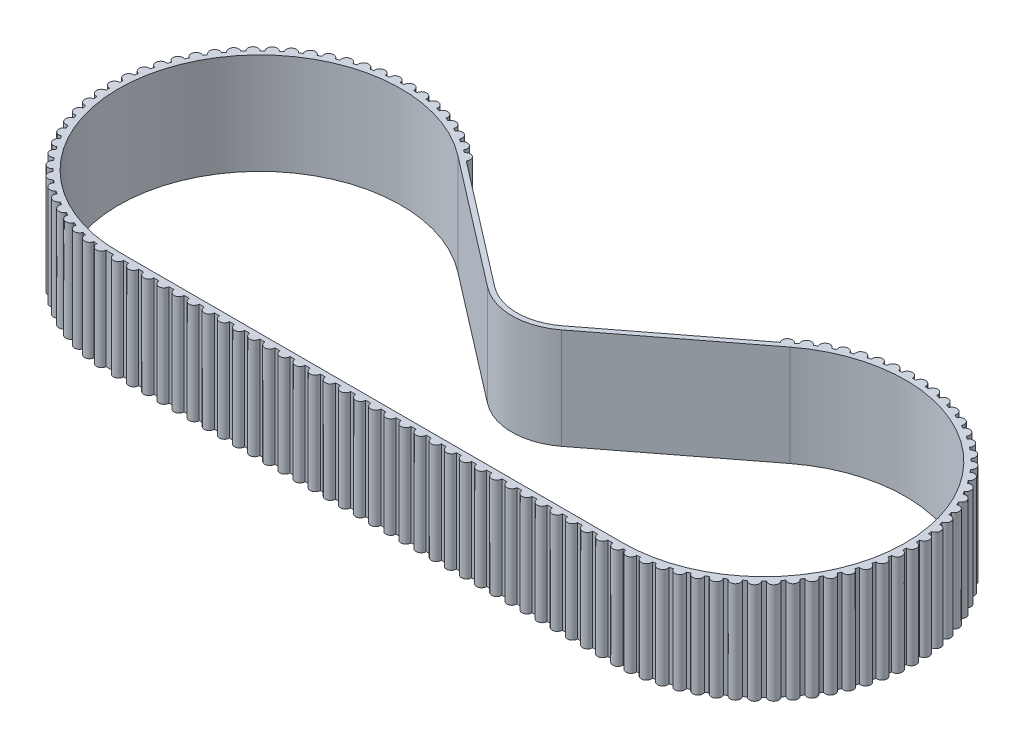
from build123d import *

# Parameters (mm, degrees)
BOSS_EXTRUDE1_DEPTH = 10


with BuildPart() as part:
    # Sketch2 → Boss-Extrude1 (new body)
    with BuildSketch(Plane(origin=(0, 0, 0), x_dir=(1, 0, 0), z_dir=(0, 1, 0))):
        with BuildLine():
            Line((1, -14.5), (1.5, -14.5))
            ThreePointArc((1.5, -14.5), (2, -15), (2.5, -14.5))
            Line((2.5, -14.5), (3, -14.5))
            ThreePointArc((3, -14.5), (3.5, -15), (4, -14.5))
            Line((4, -14.5), (4.5, -14.5))
            ThreePointArc((4.5, -14.5), (5, -15), (5.5, -14.5))
            Line((5.5, -14.5), (6, -14.5))
            ThreePointArc((6, -14.5), (6.5, -15), (7, -14.5))
            Line((7, -14.5), (7.5, -14.5))
            ThreePointArc((7.5, -14.5), (8, -15), (8.5, -14.5))
            Line((8.5, -14.5), (9, -14.5))
            ThreePointArc((9, -14.5), (9.5, -15), (10, -14.5))
            Line((10, -14.5), (10.5, -14.5))
            ThreePointArc((10.5, -14.5), (11, -15), (11.5, -14.5))
            Line((11.5, -14.5), (12, -14.5))
            ThreePointArc((12, -14.5), (12.5, -15), (13, -14.5))
            Line((13, -14.5), (13.5, -14.5))
            ThreePointArc((13.5, -14.5), (14, -15), (14.5, -14.5))
            Line((14.5, -14.5), (15, -14.5))
            ThreePointArc((15, -14.5), (15.5, -15), (16, -14.5))
            Line((16, -14.5), (16.5, -14.5))
            ThreePointArc((16.5, -14.5), (17, -15), (17.5, -14.5))
            Line((17.5, -14.5), (18, -14.5))
            ThreePointArc((18, -14.5), (18.5, -15), (19, -14.5))
            Line((19, -14.5), (19.5, -14.5))
            ThreePointArc((19.5, -14.5), (20, -15), (20.5, -14.5))
            Line((20.5, -14.5), (21, -14.5))
            ThreePointArc((21, -14.5), (21.5, -15), (22, -14.5))
            Line((22, -14.5), (22.5, -14.5))
            ThreePointArc((22.5, -14.5), (23, -15), (23.5, -14.5))
            Line((23.5, -14.5), (24, -14.5))
            ThreePointArc((24, -14.5), (24.5, -15), (25, -14.5))
            Line((25, -14.5), (25.5, -14.5))
            ThreePointArc((25.5, -14.5), (26, -15), (26.5, -14.5))
            Line((26.5, -14.5), (27, -14.5))
            ThreePointArc((27, -14.5), (27.5, -15), (28, -14.5))
            Line((28, -14.5), (28.5, -14.5))
            ThreePointArc((28.5, -14.5), (29, -15), (29.5, -14.5))
            Line((29.5, -14.5), (30, -14.5))
            ThreePointArc((30, -14.5), (30.5, -15), (31, -14.5))
            Line((31, -14.5), (31.5, -14.5))
            ThreePointArc((31.5, -14.5), (32, -15), (32.5, -14.5))
            Line((32.5, -14.5), (33, -14.5))
            ThreePointArc((33, -14.5), (33.5, -15), (34, -14.5))
            Line((34, -14.5), (34.5, -14.5))
            ThreePointArc((34.5, -14.5), (35, -15), (35.5, -14.5))
            Line((35.5, -14.5), (36, -14.5))
            ThreePointArc((36, -14.5), (36.5, -15), (37, -14.5))
            Line((37, -14.5), (37.5, -14.5))
            ThreePointArc((37.5, -14.5), (38, -15), (38.5, -14.5))
            Line((38.5, -14.5), (39, -14.5))
            ThreePointArc((39, -14.5), (39.5, -15), (40, -14.5))
            Line((40, -14.5), (40.5, -14.5))
            ThreePointArc((40.5, -14.5), (41, -15), (41.5, -14.5))
            Line((41.5, -14.5), (42, -14.5))
            ThreePointArc((42, -14.5), (42.5, -15), (43, -14.5))
            Line((43, -14.5), (43.5, -14.5))
            ThreePointArc((43.5, -14.5), (44, -15), (44.5, -14.5))
            Line((44.5, -14.5), (45, -14.5))
            ThreePointArc((45, -14.5), (45.5, -15), (46, -14.5))
            Line((46, -14.5), (46.5, -14.5))
            ThreePointArc((46.5, -14.5), (47, -15), (47.5, -14.5))
            Line((47.5, -14.5), (48, -14.5))
            ThreePointArc((48, -14.5), (48.5, -15), (49, -14.5))
            Line((49, -14.5), (49.5, -14.5))
            ThreePointArc((49.5, -14.5), (50.004310505, -14.999981419), (50.499925678, -14.49137931))
            ThreePointArc((50.499925678, -14.49137931), (50.626462716, -14.486460729), (50.752951974, -14.480437263))
            ThreePointArc((50.752951974, -14.480437263), (51.294919506, -14.944001588), (51.749070658, -14.394122128))
            ThreePointArc((51.749070658, -14.394122128), (51.923307681, -14.371878359), (52.097262467, -14.347525576))
            ThreePointArc((52.097262467, -14.347525576), (52.680018243, -14.758641612), (53.081025655, -14.168884251))
            ThreePointArc((53.081025655, -14.168884251), (53.252436496, -14.130522171), (53.423370055, -14.090086496))
            ThreePointArc((53.423370055, -14.090086496), (54.041856126, -14.445186017), (54.386239311, -13.820669474))
            ThreePointArc((54.386239311, -13.820669474), (54.553336232, -13.766522043), (54.71976497, -13.710354431))
            ThreePointArc((54.71976497, -13.710354431), (55.368613271, -14.006355399), (55.6533832, -13.35250008))
            ThreePointArc((55.6533832, -13.35250008), (55.814715907, -13.283037263), (55.975195329, -13.211625214))
            ThreePointArc((55.975195329, -13.211625214), (56.648774268, -13.445958528), (56.87145932, -12.768439482))
            ThreePointArc((56.87145932, -12.768439482), (57.025627548, -12.684264171), (57.178764794, -12.598227496))
            ThreePointArc((57.178764794, -12.598227496), (57.871228135, -12.768859293), (58.029895546, -12.073556954))
            ThreePointArc((58.029895546, -12.073556954), (58.175561212, -11.975399737), (58.320027148, -11.87548518))
            ThreePointArc((58.320027148, -11.87548518), (59.025364751, -11.980934484), (59.118637388, -11.273883634))
            ThreePointArc((59.118637388, -11.273883634), (59.254536207, -11.162596454), (59.389076961, -11.049671209))
            ThreePointArc((59.389076961, -11.049671209), (60.101166943, -11.089022788), (60.128235259, -10.376360178))
            ThreePointArc((60.128235259, -10.376360178), (60.253187716, -10.252908937), (60.37663556, -10.127953123))
            ThreePointArc((60.37663556, -10.127953123), (61.089297434, -10.10086543), (61.049926493, -9.388776518))
            ThreePointArc((61.049926493, -9.388776518), (61.16284808, -9.254232693), (61.274131565, -9.118330848))
            ThreePointArc((61.274131565, -9.118330848), (61.981179879, -9.025038987), (61.875711396, -8.319704251))
            ThreePointArc((61.875711396, -8.319704251), (61.975622026, -8.175235599), (62.073775282, -8.029567264))
            ThreePointArc((62.073775282, -8.029567264), (62.769073306, -7.870880948), (62.598422681, -7.178422246))
            ThreePointArc((62.598422681, -7.178422246), (62.684455192, -7.025282661), (62.768626312, -6.871112145))
            ThreePointArc((62.768626312, -6.871112145), (63.446139303, -6.648408671), (63.211787674, -5.974836103))
            ThreePointArc((63.211787674, -5.974836103), (63.283195359, -5.81435474), (63.35265379, -5.653020144))
            ThreePointArc((63.35265379, -5.653020144), (64.006501365, -5.368232437), (63.710482756, -4.719392185))
            ThreePointArc((63.710482756, -4.719392185), (63.766645843, -4.55296192), (63.82078873, -4.385863526))
            ThreePointArc((63.82078873, -4.385863526), (64.445295909, -4.041463362), (64.090179572, -3.422986946))
            ThreePointArc((64.090179572, -3.422986946), (64.1306106, -3.252052287), (64.168968018, -3.080640404))
            ThreePointArc((64.168968018, -3.080640404), (64.758714476, -2.679616956), (64.347582595, -2.096872358))
            ThreePointArc((64.347582595, -2.096872358), (64.371930648, -1.92291691), (64.39416968, -1.748679282))
            ThreePointArc((64.39416968, -1.748679282), (64.944036792, -1.29451318), (64.48045773, -0.752558252))
            ThreePointArc((64.48045773, -0.752558252), (64.488511484, -0.577091838), (64.494439107, -0.401540738))
            ThreePointArc((64.494439107, -0.401540738), (64.999654377, 0.101826147), (64.487651707, 0.598287581))
            ThreePointArc((64.487651707, 0.598287581), (64.479341258, 0.773742025), (64.468906026, 0.949082925))
            ThreePointArc((64.468906026, 0.949082925), (64.925084507, 1.497281688), (64.369102085, 1.943940658))
            ThreePointArc((64.369102085, 1.943940658), (64.344499564, 2.117860299), (64.317792048, 2.291469152))
            ThreePointArc((64.317792048, 2.291469152), (64.720974401, 2.879741776), (64.1258378, 3.272721567))
            ThreePointArc((64.1258378, 3.272721567), (64.085156742, 3.443596893), (64.042408745, 3.613966885))
            ThreePointArc((64.042408745, 3.613966885), (64.389095603, 4.237207538), (63.759970231, 4.573097335))
            ThreePointArc((63.759970231, 4.573097335), (63.703563721, 4.739445257), (63.645146269, 4.905097685))
            ThreePointArc((63.645146269, 4.905097685), (63.932328612, 5.557897035), (63.274674876, 5.833781529))
            ThreePointArc((63.274674876, 5.833781529), (63.203032487, 5.994158252), (63.129452606, 6.153655358))
            ThreePointArc((63.129452606, 6.153655358), (63.354637873, 6.830347522), (62.674163791, 7.043832211))
            ThreePointArc((62.674163791, 7.043832211), (62.587907332, 7.196845768), (62.499803649, 7.348803218))
            ThreePointArc((62.499803649, 7.348803218), (62.661037376, 8.043514939), (61.963649028, 8.192746911))
            ThreePointArc((61.963649028, 8.192746911), (61.863527151, 8.337069242), (61.76166435, 8.480168142))
            ThreePointArc((61.76166435, 8.480168142), (61.85754713, 9.186869764), (61.149297404, 9.270553781))
            ThreePointArc((61.149297404, 9.270553781), (61.036179103, 9.40493226), (60.921441288, 9.537930603))
            ThreePointArc((60.921441288, 9.537930603), (60.95114092, 10.250488405), (60.238176973, 10.267898143))
            ThreePointArc((60.238176973, 10.267898143), (60.113044043, 10.39116645), (59.986427066, 10.512909895))
            ThreePointArc((59.986427066, 10.512909895), (59.949685776, 11.22513933), (59.23819568, 11.176123683))
            ThreePointArc((59.23819568, 11.176123683), (59.102134196, 11.287211927), (58.96473701, 11.396643819))
            ThreePointArc((58.96473701, 11.396643819), (58.861873689, 12.102363187), (58.158032727, 11.987347581))
            ThreePointArc((58.158032727, 11.987347581), (58.012223615, 12.085291587), (57.865238742, 12.181462126))
            ThreePointArc((57.865238742, 12.181462126), (57.697146178, 12.874546233), (57.007063241, 12.694528929))
            ThreePointArc((57.007063241, 12.694528929), (56.852772032, 12.778478606), (56.697475207, 12.860553093))
            ThreePointArc((56.697475207, 12.860553093), (56.465612336, 13.53498641), (55.795276905, 13.291529844))
            ThreePointArc((55.795276905, 13.291529844), (55.633842748, 13.360756561), (55.471581848, 13.428022642))
            ThreePointArc((55.471581848, 13.428022642), (55.177961093, 14.077951517), (54.533191253, 13.773168737))
            ThreePointArc((54.533191253, 13.773168737), (54.366015294, 13.827071651), (54.19819864, 13.8789455))
            ThreePointArc((54.19819864, 13.8789455), (53.845368443, 14.498728963), (53.231760385, 14.13526529))
            ThreePointArc((53.231760385, 14.13526529), (53.060293605, 14.173376558), (52.888377739, 14.209407941))
            ThreePointArc((52.888377739, 14.209407941), (52.479400441, 14.793666667), (51.902279894, 14.374676734))
            ThreePointArc((51.902279894, 14.374676734), (51.728010515, 14.396665574), (51.553487558, 14.416541763))
            ThreePointArc((51.553487558, 14.416541763), (51.091912821, 14.960204758), (50.556288823, 14.489325131))
            ThreePointArc((50.556288823, 14.489325131), (50.380729393, 14.495000694), (50.205114093, 14.498549176))
            ThreePointArc((50.205114093, 14.498549176), (49.694948092, 14.99689779), (49.20546952, 14.478215405))
            ThreePointArc((49.20546952, 14.478215405), (49.030143783, 14.467528432), (48.854960368, 14.454718408))
            ThreePointArc((48.854960368, 14.454718408), (48.30063102, 14.903427293), (47.861546235, 14.341443982))
            ThreePointArc((47.861546235, 14.341443982), (47.687975907, 14.314487228), (47.514744859, 14.285429881))
            ThreePointArc((47.514744859, 14.285429881), (46.92106339, 14.680604529), (46.536183369, 14.080197951))
            ThreePointArc((46.536183369, 14.080197951), (46.365874929, 14.037205383), (46.196099783, 13.992152913))
            ThreePointArc((46.196099783, 13.992152913), (45.56821897, 14.33036346), (45.240884226, 13.696744761))
            ThreePointArc((45.240884226, 13.696744761), (45.075315845, 13.638089528), (44.91047014, 13.577432961))
            ThreePointArc((44.91047014, 13.577432961), (44.253839589, 13.855743954), (43.986891181, 13.194412542))
            ThreePointArc((43.986891181, 13.194412542), (43.827499885, 13.120603733), (43.669014378, 13.04486953))
            ThreePointArc((43.669014378, 13.04486953), (42.989333224, 13.260865408), (42.785088094, 12.577561218))
            ThreePointArc((42.785088094, 12.577561218), (42.633257299, 12.489239447), (42.482507543, 12.399084932))
            ThreePointArc((42.482507543, 12.399084932), (41.785674987, 12.550890987), (41.645905851, 11.851544665))
            ThreePointArc((41.645905851, 11.851544665), (41.502953351, 11.74947651), (41.361247759, 11.645684167))
            ThreePointArc((41.361247759, 11.645684167), (40.653311863, 11.731982819), (40.57923183, 11.022664246))
            Line((40.57923183, 11.022664246), (28.353810415, 1.640876728))
            ThreePointArc((28.353810415, 1.640876728), (25, 0.5), (21.646189585, 1.640876728))
            Line((21.646189585, 1.640876728), (9.432679246, 11.037674115))
            ThreePointArc((9.432679246, 11.037674115), (9.339137452, 11.73788096), (8.638752241, 11.645684167))
            ThreePointArc((8.638752241, 11.645684167), (8.497046649, 11.74947651), (8.354094149, 11.851544665))
            ThreePointArc((8.354094149, 11.851544665), (8.214325013, 12.550890987), (7.517492457, 12.399084932))
            ThreePointArc((7.517492457, 12.399084932), (7.366742701, 12.489239447), (7.214911906, 12.577561218))
            ThreePointArc((7.214911906, 12.577561218), (7.010666776, 13.260865408), (6.330985622, 13.04486953))
            ThreePointArc((6.330985622, 13.04486953), (6.172500115, 13.120603733), (6.013108819, 13.194412542))
            ThreePointArc((6.013108819, 13.194412542), (5.746160411, 13.855743954), (5.08952986, 13.577432961))
            ThreePointArc((5.08952986, 13.577432961), (4.924684155, 13.638089528), (4.759115774, 13.696744761))
            ThreePointArc((4.759115774, 13.696744761), (4.43178103, 14.33036346), (3.803900217, 13.992152913))
            ThreePointArc((3.803900217, 13.992152913), (3.634125071, 14.037205383), (3.463816631, 14.080197951))
            ThreePointArc((3.463816631, 14.080197951), (3.07893661, 14.680604529), (2.485255141, 14.285429881))
            ThreePointArc((2.485255141, 14.285429881), (2.312024093, 14.314487228), (2.138453765, 14.341443982))
            ThreePointArc((2.138453765, 14.341443982), (1.69936898, 14.903427293), (1.145039632, 14.454718408))
            ThreePointArc((1.145039632, 14.454718408), (0.969856217, 14.467528432), (0.79453048, 14.478215405))
            ThreePointArc((0.79453048, 14.478215405), (0.305051908, 14.99689779), (-0.205114093, 14.498549176))
            ThreePointArc((-0.205114093, 14.498549176), (-0.380729393, 14.495000694), (-0.556288823, 14.489325131))
            ThreePointArc((-0.556288823, 14.489325131), (-1.091912821, 14.960204758), (-1.553487558, 14.416541763))
            ThreePointArc((-1.553487558, 14.416541763), (-1.728010515, 14.396665574), (-1.902279894, 14.374676734))
            ThreePointArc((-1.902279894, 14.374676734), (-2.479400441, 14.793666667), (-2.888377739, 14.209407941))
            ThreePointArc((-2.888377739, 14.209407941), (-3.060293605, 14.173376558), (-3.231760385, 14.13526529))
            ThreePointArc((-3.231760385, 14.13526529), (-3.845368443, 14.498728963), (-4.19819864, 13.8789455))
            ThreePointArc((-4.19819864, 13.8789455), (-4.366015294, 13.827071651), (-4.533191253, 13.773168737))
            ThreePointArc((-4.533191253, 13.773168737), (-5.177961093, 14.077951517), (-5.471581848, 13.428022642))
            ThreePointArc((-5.471581848, 13.428022642), (-5.633842748, 13.360756561), (-5.795276905, 13.291529844))
            ThreePointArc((-5.795276905, 13.291529844), (-6.465612336, 13.53498641), (-6.697475207, 12.860553093))
            ThreePointArc((-6.697475207, 12.860553093), (-6.852772032, 12.778478606), (-7.007063241, 12.694528929))
            ThreePointArc((-7.007063241, 12.694528929), (-7.697146178, 12.874546233), (-7.865238742, 12.181462126))
            ThreePointArc((-7.865238742, 12.181462126), (-8.012223615, 12.085291587), (-8.158032727, 11.987347581))
            ThreePointArc((-8.158032727, 11.987347581), (-8.861873689, 12.102363187), (-8.96473701, 11.396643819))
            ThreePointArc((-8.96473701, 11.396643819), (-9.102134196, 11.287211927), (-9.23819568, 11.176123683))
            ThreePointArc((-9.23819568, 11.176123683), (-9.949685776, 11.22513933), (-9.986427066, 10.512909895))
            ThreePointArc((-9.986427066, 10.512909895), (-10.113044043, 10.39116645), (-10.238176973, 10.267898143))
            ThreePointArc((-10.238176973, 10.267898143), (-10.95114092, 10.250488405), (-10.921441288, 9.537930603))
            ThreePointArc((-10.921441288, 9.537930603), (-11.036179103, 9.40493226), (-11.149297404, 9.270553781))
            ThreePointArc((-11.149297404, 9.270553781), (-11.85754713, 9.186869764), (-11.76166435, 8.480168142))
            ThreePointArc((-11.76166435, 8.480168142), (-11.863527151, 8.337069242), (-11.963649028, 8.192746911))
            ThreePointArc((-11.963649028, 8.192746911), (-12.661037376, 8.043514939), (-12.499803649, 7.348803218))
            ThreePointArc((-12.499803649, 7.348803218), (-12.587907332, 7.196845768), (-12.674163791, 7.043832211))
            ThreePointArc((-12.674163791, 7.043832211), (-13.354637873, 6.830347522), (-13.129452606, 6.153655358))
            ThreePointArc((-13.129452606, 6.153655358), (-13.203032487, 5.994158252), (-13.274674876, 5.833781529))
            ThreePointArc((-13.274674876, 5.833781529), (-13.932328612, 5.557897035), (-13.645146269, 4.905097685))
            ThreePointArc((-13.645146269, 4.905097685), (-13.703563721, 4.739445257), (-13.759970231, 4.573097335))
            ThreePointArc((-13.759970231, 4.573097335), (-14.389095603, 4.237207538), (-14.042408745, 3.613966885))
            ThreePointArc((-14.042408745, 3.613966885), (-14.085156742, 3.443596893), (-14.1258378, 3.272721567))
            ThreePointArc((-14.1258378, 3.272721567), (-14.720974401, 2.879741776), (-14.317792048, 2.291469152))
            ThreePointArc((-14.317792048, 2.291469152), (-14.344499564, 2.117860299), (-14.369102085, 1.943940658))
            ThreePointArc((-14.369102085, 1.943940658), (-14.925084507, 1.497281688), (-14.468906026, 0.949082925))
            ThreePointArc((-14.468906026, 0.949082925), (-14.479341258, 0.773742025), (-14.487651707, 0.598287581))
            ThreePointArc((-14.487651707, 0.598287581), (-14.999654377, 0.101826147), (-14.494439107, -0.401540738))
            ThreePointArc((-14.494439107, -0.401540738), (-14.488511484, -0.577091838), (-14.48045773, -0.752558252))
            ThreePointArc((-14.48045773, -0.752558252), (-14.944036792, -1.29451318), (-14.39416968, -1.748679282))
            ThreePointArc((-14.39416968, -1.748679282), (-14.371930648, -1.92291691), (-14.347582595, -2.096872358))
            ThreePointArc((-14.347582595, -2.096872358), (-14.758714476, -2.679616956), (-14.168968018, -3.080640404))
            ThreePointArc((-14.168968018, -3.080640404), (-14.1306106, -3.252052287), (-14.090179572, -3.422986946))
            ThreePointArc((-14.090179572, -3.422986946), (-14.445295909, -4.041463362), (-13.82078873, -4.385863526))
            ThreePointArc((-13.82078873, -4.385863526), (-13.766645843, -4.55296192), (-13.710482756, -4.719392185))
            ThreePointArc((-13.710482756, -4.719392185), (-14.006501365, -5.368232437), (-13.35265379, -5.653020144))
            ThreePointArc((-13.35265379, -5.653020144), (-13.283195359, -5.81435474), (-13.211787674, -5.974836103))
            ThreePointArc((-13.211787674, -5.974836103), (-13.446139303, -6.648408671), (-12.768626312, -6.871112145))
            ThreePointArc((-12.768626312, -6.871112145), (-12.684455192, -7.025282661), (-12.598422681, -7.178422246))
            ThreePointArc((-12.598422681, -7.178422246), (-12.769073306, -7.870880948), (-12.073775282, -8.029567264))
            ThreePointArc((-12.073775282, -8.029567264), (-11.975622026, -8.175235599), (-11.875711396, -8.319704251))
            ThreePointArc((-11.875711396, -8.319704251), (-11.981179879, -9.025038987), (-11.274131565, -9.118330848))
            ThreePointArc((-11.274131565, -9.118330848), (-11.16284808, -9.254232693), (-11.049926493, -9.388776518))
            ThreePointArc((-11.049926493, -9.388776518), (-11.089297434, -10.10086543), (-10.37663556, -10.127953123))
            ThreePointArc((-10.37663556, -10.127953123), (-10.253187716, -10.252908937), (-10.128235259, -10.376360178))
            ThreePointArc((-10.128235259, -10.376360178), (-10.101166943, -11.089022788), (-9.389076961, -11.049671209))
            ThreePointArc((-9.389076961, -11.049671209), (-9.254536207, -11.162596454), (-9.118637388, -11.273883634))
            ThreePointArc((-9.118637388, -11.273883634), (-9.025364751, -11.980934484), (-8.320027148, -11.87548518))
            ThreePointArc((-8.320027148, -11.87548518), (-8.175561212, -11.975399737), (-8.029895546, -12.073556954))
            ThreePointArc((-8.029895546, -12.073556954), (-7.871228135, -12.768859293), (-7.178764794, -12.598227496))
            ThreePointArc((-7.178764794, -12.598227496), (-7.025627548, -12.684264171), (-6.87145932, -12.768439482))
            ThreePointArc((-6.87145932, -12.768439482), (-6.648774268, -13.445958528), (-5.975195329, -13.211625214))
            ThreePointArc((-5.975195329, -13.211625214), (-5.814715907, -13.283037263), (-5.6533832, -13.35250008))
            ThreePointArc((-5.6533832, -13.35250008), (-5.368613271, -14.006355399), (-4.71976497, -13.710354431))
            ThreePointArc((-4.71976497, -13.710354431), (-4.553336232, -13.766522043), (-4.386239311, -13.820669474))
            ThreePointArc((-4.386239311, -13.820669474), (-4.041856126, -14.445186017), (-3.423370055, -14.090086496))
            ThreePointArc((-3.423370055, -14.090086496), (-3.252436458, -14.130522178), (-3.081025578, -14.168884264))
            ThreePointArc((-3.081025578, -14.168884264), (-2.680018229, -14.758641535), (-2.097262543, -14.347525561))
            ThreePointArc((-2.097262543, -14.347525561), (-1.923307719, -14.371878352), (-1.749070658, -14.394122128))
            ThreePointArc((-1.749070658, -14.394122128), (-1.294919506, -14.944001588), (-0.752951974, -14.480437263))
            ThreePointArc((-0.752951974, -14.480437263), (-0.376603032, -14.495108491), (0, -14.5))
            ThreePointArc((0, -14.5), (0.5, -15), (1, -14.5))
        make_face()
        with BuildLine():
            Line((28.658702271, 1.244592794), (41.463028035, 11.095950147))
            ThreePointArc((41.463028035, 11.095950147), (63.254118267, 4.508697037), (50, -14))
            Line((50, -14), (0, -14))
            ThreePointArc((0, -14), (-13.254118267, 4.508697037), (8.536971965, 11.095950147))
            Line((8.536971965, 11.095950147), (21.341297729, 1.244592794))
            ThreePointArc((21.341297729, 1.244592794), (25, 0), (28.658702271, 1.244592794))
        make_face(mode=Mode.SUBTRACT)
    extrude(amount=BOSS_EXTRUDE1_DEPTH)


solid = part.part
